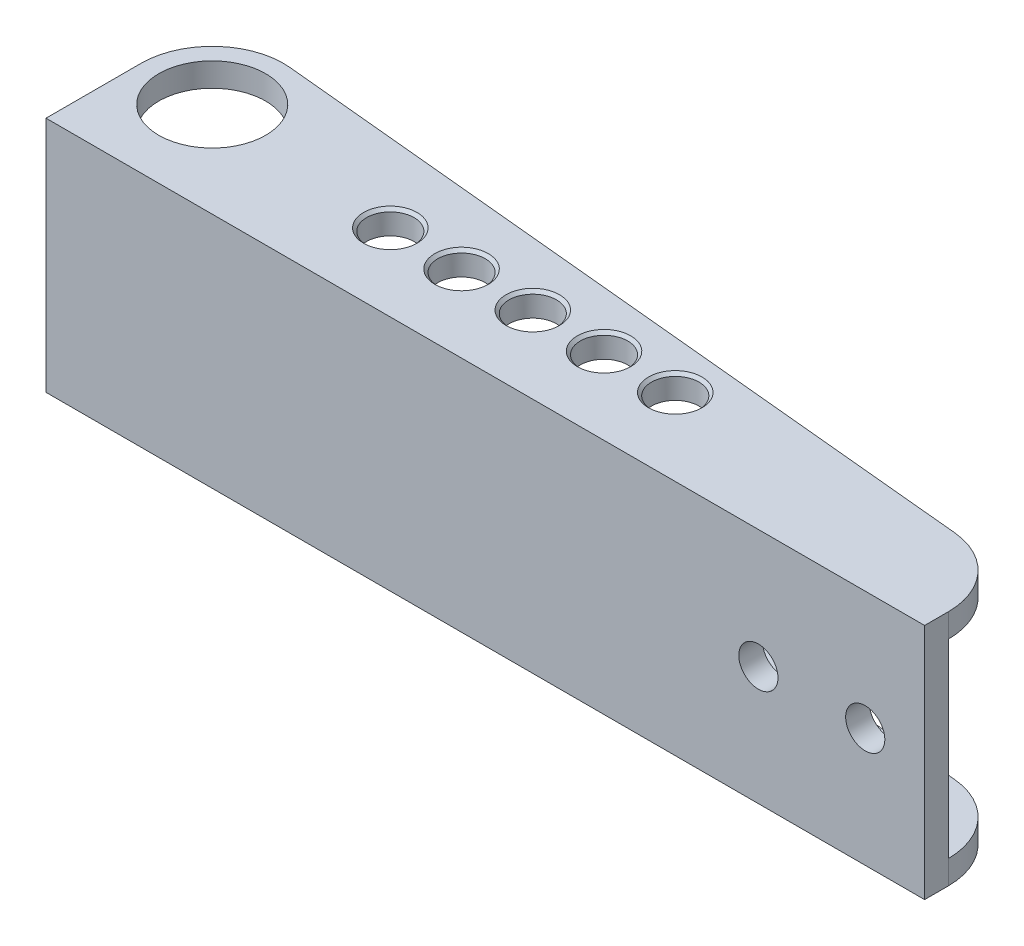
from build123d import *

# Parameters (mm, degrees)
ESQUISSE1_W                 = 148
ESQUISSE1_H                 = 40
BOSS_EXTRU_1_DEPTH          = 30
ESQUISSE2_OUTSIDE_W         = 181.244
ESQUISSE2_OUTSIDE_H         = 63.244
ENL_V_MAT_EXTRU_1_DEPTH     = 41
ESQUISSE3_W                 = 24
ESQUISSE3_H                 = 32
ENL_V_MAT_EXTRU_3_DEPTH     = 149
ESQUISSE4_R                 = 9
ESQUISSE4_R_2               = 4
ENL_V_MAT_EXTRU_4_DEPTH     = 41
CHANFREIN1_SIZE             = 0.5
TROU_TARAUD_M31_D           = 2.5
TROU_TARAUD_M31_DEPTH       = 8.5
TROU_TARAUD_M31_CSINK_D     = 3.05
TROU_TARAUD_M31_CSINK_ANGLE = 90
TROU_TARAUD_M31_TIP         = 0.751075774
D_GAGEMENT_M61_D            = 6.6


with BuildPart() as part:
    # Esquisse1 → Boss.-Extru.1 (new body)
    with BuildSketch(Plane.XY):
        Rectangle(ESQUISSE1_W, ESQUISSE1_H)
    extrude(amount=BOSS_EXTRU_1_DEPTH)

    # Esquisse2 outside → Enlèv. mat.-Extru.1 (cut, through all)
    with BuildSketch(Plane(origin=(0, 20, 0), x_dir=(1, 0, 0), z_dir=(0, 1, 0))):
        with Locations((0, -15)):
            Rectangle(ESQUISSE2_OUTSIDE_W, ESQUISSE2_OUTSIDE_H)
        with BuildLine():
            Line((-74, -14), (-74, -30))
            Line((-74, -30), (74, -30))
            Line((74, -30), (74, -26))
            ThreePointArc((74, -26), (70.853760815, -17.858682375), (63.050333897, -13.948899514))
            Line((63.050333897, -13.948899514), (-60.853344924, -2.054909706))
            ThreePointArc((-60.853344924, -2.054909706), (-70.06970071, -5.118562591), (-74, -14))
        make_face(mode=Mode.SUBTRACT)
    extrude(amount=-ENL_V_MAT_EXTRU_1_DEPTH, mode=Mode.SUBTRACT)

    # Esquisse3 → Enlèv. mat.-Extru.3 (cut, through all)
    with BuildSketch(Plane.ZY.offset(74)):
        with Locations((14, 0)):
            Rectangle(ESQUISSE3_W, ESQUISSE3_H)
    extrude(amount=-ENL_V_MAT_EXTRU_3_DEPTH, mode=Mode.SUBTRACT)

    # Esquisse4 → Enlèv. mat.-Extru.4 (cut, through all)
    with BuildSketch(Plane(origin=(0, 20, 0), x_dir=(1, 0, 0), z_dir=(0, 1, 0))):
        with Locations((-62, -14)):
            Circle(ESQUISSE4_R)
        with Locations((-29, -17)):
            Circle(ESQUISSE4_R_2)
        with Locations((-17, -17)):
            Circle(ESQUISSE4_R_2)
        with Locations((-5, -17)):
            Circle(ESQUISSE4_R_2)
        with Locations((7, -17)):
            Circle(ESQUISSE4_R_2)
        with Locations((19, -17)):
            Circle(ESQUISSE4_R_2)
    extrude(amount=-ENL_V_MAT_EXTRU_4_DEPTH, mode=Mode.SUBTRACT)

    # Chanfrein1
    chanfrein1_edges = [part.edges().sort_by_distance(p)[0] for p in [
        (3, 20, 17),
        (15, -20, 17),
        (15, 20, 17),
        (-33, -20, 17),
        (-33, 20, 17),
        (-21, -20, 17),
        (-21, 20, 17),
        (-9, -20, 17),
        (-9, 20, 17),
        (3, -20, 17),
    ]]
    chamfer(chanfrein1_edges, length=CHANFREIN1_SIZE)

    # Trou taraudé M31
    with Locations(Plane(origin=(0, -20, 0), x_dir=(-1, 0, 0), z_dir=(0, -1, 0))):
        with Locations((29, -10), (23, -26), (35, -26)):
            CounterSinkHole(TROU_TARAUD_M31_D / 2, TROU_TARAUD_M31_CSINK_D / 2, depth=TROU_TARAUD_M31_DEPTH, counter_sink_angle=TROU_TARAUD_M31_CSINK_ANGLE)
            with Locations((0, 0, -(TROU_TARAUD_M31_DEPTH + TROU_TARAUD_M31_TIP / 2))):  # 118° drill point
                Cone(0, TROU_TARAUD_M31_D / 2, TROU_TARAUD_M31_TIP, mode=Mode.SUBTRACT)

    # Dégagement M61 (through all)
    with Locations(Plane.XY.offset(30)):
        with Locations((46, 0), (64, 0)):
            Hole(D_GAGEMENT_M61_D / 2)


solid = part.part
